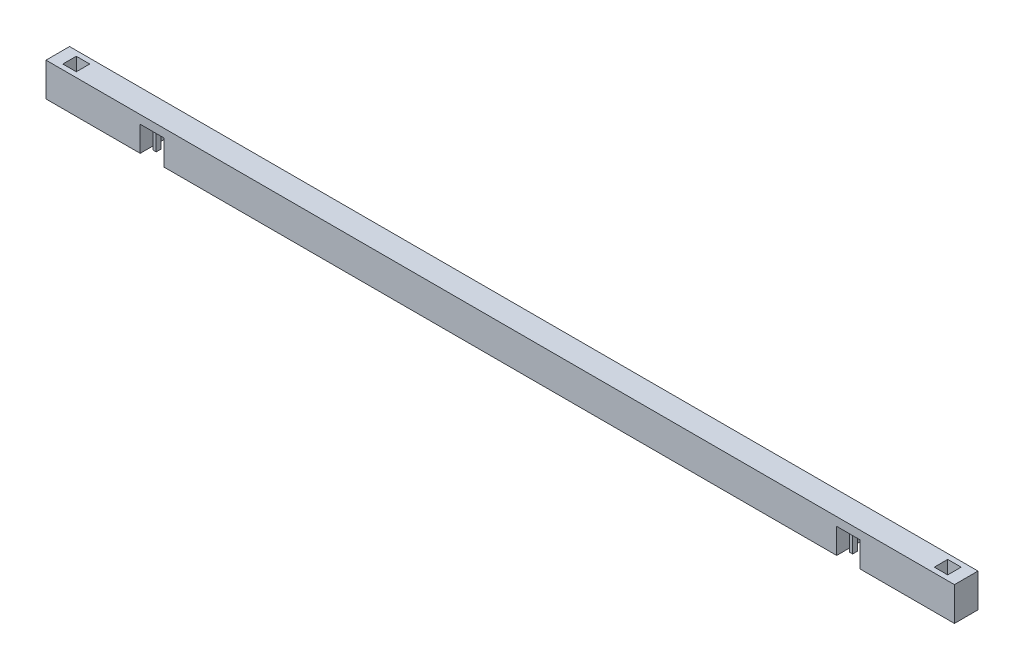
from build123d import *

# Parameters (mm, degrees)
SKETCH_1_W             = 5400
SKETCH_1_H             = 140
EXTRUDE_1_DEPTH        = 200
SKETCH_2_W             = 20
SKETCH_2_H             = 30
EXTRUDE_2_DEPTH        = 150
SKETCH_3_W             = 140
SKETCH_3_H             = 140
SKETCH_3_W_2           = 20
SKETCH_3_H_2           = 30
CUT_EXTRUDE_1_DEPTH    = 150
SKETCH_4_W             = 300
SKETCH_4_H             = 300
CUT_EXTRUDE_4_DEPTH    = 141
PATTERN_LINEAR_3_COUNT = 2
PATTERN_LINEAR_3_PITCH = 4140
SKETCH_5_W             = 80
SKETCH_5_H             = 80
CUT_EXTRUDE_3_DEPTH    = 100


with BuildPart() as part:
    # 草图1 → 凸台-拉伸1 (new body)
    with BuildSketch(Plane(origin=(0, 0, 0), x_dir=(1, 0, 0), z_dir=(0, 1, 0))):
        with Locations((2700, 70)):
            Rectangle(SKETCH_1_W, SKETCH_1_H)
    extrude(amount=EXTRUDE_1_DEPTH)

    # 草图2 → 凸台-拉伸2 (add)
    with BuildSketch(Plane.XZ):
        with Locations((590, -70)):
            Rectangle(SKETCH_2_W, SKETCH_2_H)
        with Locations((670, -70)):
            Rectangle(SKETCH_2_W, SKETCH_2_H)
    extrude(amount=EXTRUDE_2_DEPTH)

    # 草图3 → 切除-拉伸1 (cut)
    with BuildSketch(Plane.XZ):
        with Locations((630, -70)):
            Rectangle(SKETCH_3_W, SKETCH_3_H)
        with Locations((590, -70)):
            Rectangle(SKETCH_3_W_2, SKETCH_3_H_2, mode=Mode.SUBTRACT)
        with Locations((670, -70)):
            Rectangle(SKETCH_3_W_2, SKETCH_3_H_2, mode=Mode.SUBTRACT)
    cut_extrude_1 = extrude(amount=-CUT_EXTRUDE_1_DEPTH, mode=Mode.SUBTRACT)

    # 草图4 → 切除-拉伸4 (cut, through all)
    with BuildSketch(Plane(origin=(0, 0, -140), x_dir=(-1, 0, 0), z_dir=(0, 0, -1))):
        with Locations((-710, -150)):
            Rectangle(SKETCH_4_W, SKETCH_4_H)
    extrude(amount=-CUT_EXTRUDE_4_DEPTH, mode=Mode.SUBTRACT)

    # 阵列(线性)3: 切除-拉伸1 ×2
    with Locations(*[(i * PATTERN_LINEAR_3_PITCH, 0, 0) for i in range(1, PATTERN_LINEAR_3_COUNT)]):
        add(cut_extrude_1, mode=Mode.SUBTRACT)

    # 草图5 → 切除-拉伸3 (cut)
    with BuildSketch(Plane(origin=(0, 200, 0), x_dir=(1, 0, 0), z_dir=(0, 1, 0))):
        with Locations((5290, 70)):
            Rectangle(SKETCH_5_W, SKETCH_5_H)
    cut_extrude_3 = extrude(amount=-CUT_EXTRUDE_3_DEPTH, mode=Mode.SUBTRACT)

    # 镜向1: 切除-拉伸3 across plane
    add(cut_extrude_3.mirror(Plane(origin=(2700, 0, 0), x_dir=(0, 0, 1), z_dir=(1, 0, 0))), mode=Mode.SUBTRACT)


solid = part.part
